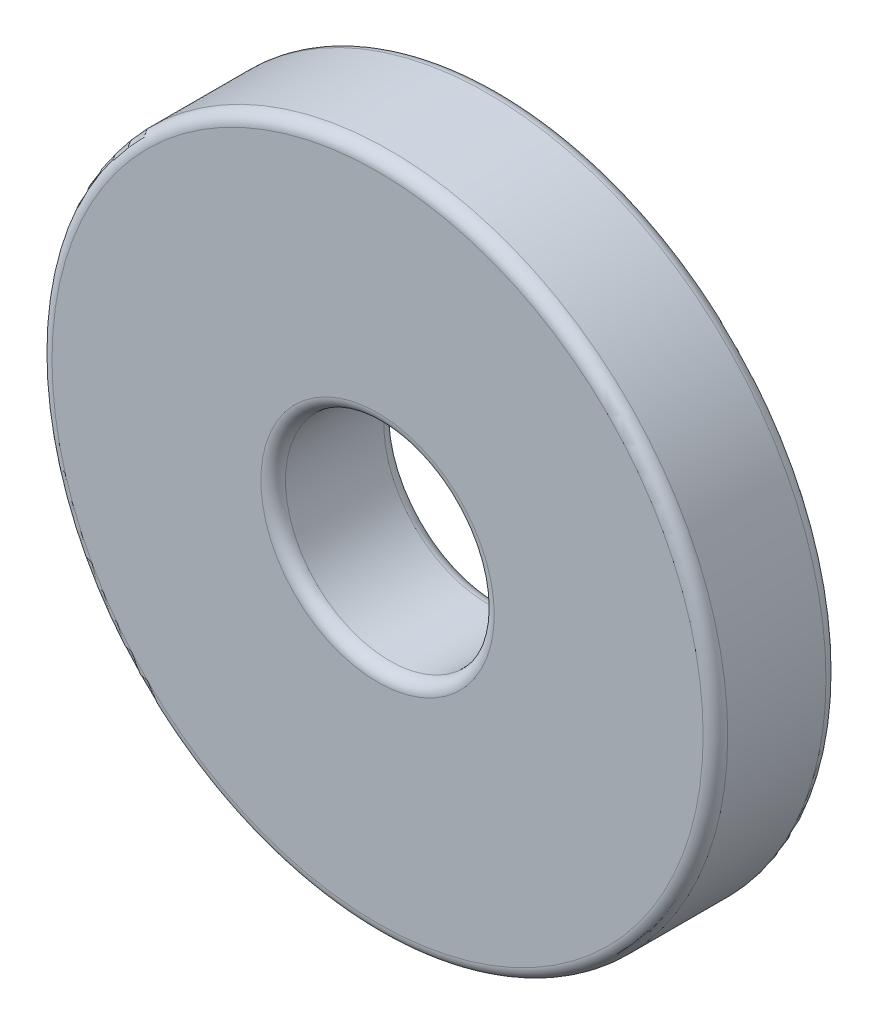
from build123d import *

# Parameters (mm, degrees)
SKETCH1_R           = 27.5
SKETCH1_R_2         = 8.5
BOSS_EXTRUDE1_DEPTH = 10
FILLET1_R           = 1


with BuildPart() as part:
    # Sketch1 → Boss-Extrude1 (new body)
    with BuildSketch(Plane.XY):
        Circle(SKETCH1_R)
        Circle(SKETCH1_R_2, mode=Mode.SUBTRACT)
    extrude(amount=BOSS_EXTRUDE1_DEPTH)

    # Fillet1
    fillet1_edges = [part.edges().sort_by_distance(p)[0] for p in [
        (-27.5, 0, 0),
        (-27.5, 0, 10),
        (-8.5, 0, 0),
        (-8.5, 0, 10),
    ]]
    fillet(fillet1_edges, radius=FILLET1_R)


solid = part.part
